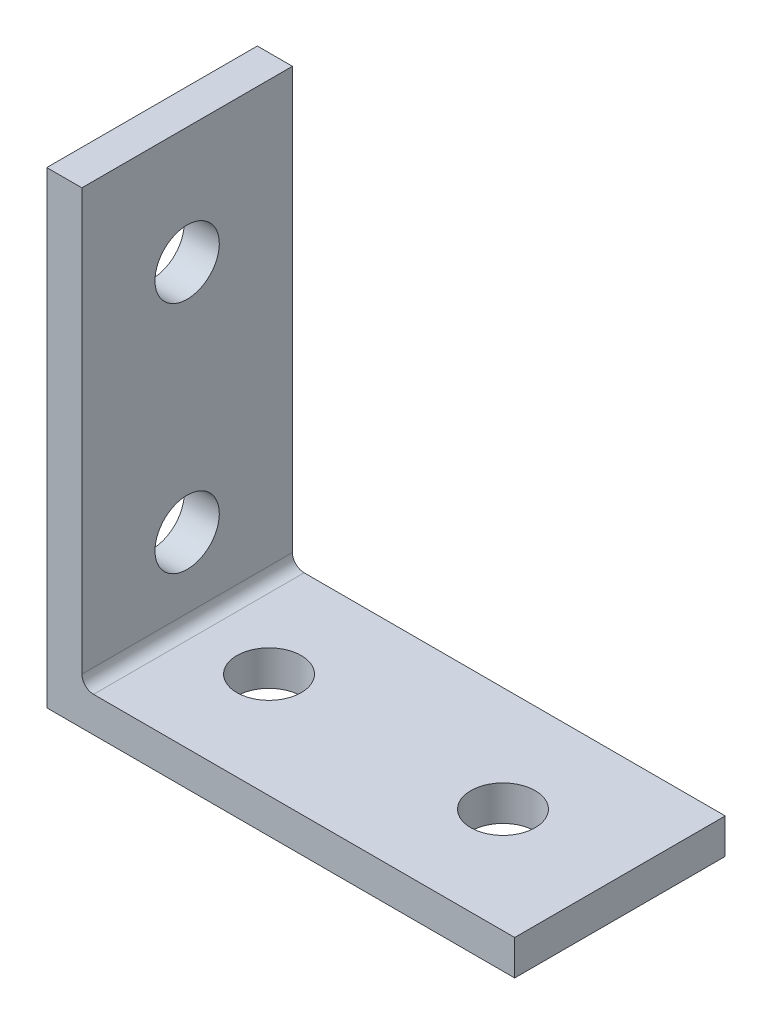
from build123d import *

# Parameters (mm, degrees)
BOSS_EXTRUDE1_DEPTH = 9
SKETCH2_R           = 2.75
CUT_EXTRUDE1_DEPTH  = 4
SKETCH3_R           = 2.75
CUT_EXTRUDE2_DEPTH  = 4


with BuildPart() as part:
    # Sketch1 → Boss-Extrude1 (new body, symmetric)
    with BuildSketch(Plane.XY):
        with BuildLine():
            Line((0, 0), (0, 40))
            Line((0, 40), (3, 40))
            Line((3, 40), (3, 4))
            ThreePointArc((3, 4), (3.292893219, 3.292893219), (4, 3))
            Line((4, 3), (40, 3))
            Line((40, 3), (40, 0))
            Line((40, 0), (0, 0))
        make_face()
    extrude(amount=BOSS_EXTRUDE1_DEPTH, both=True)

    # Sketch2 → Cut-Extrude1 (cut, through all)
    with BuildSketch(Plane(origin=(3, 0, 0), x_dir=(0, 0, -1), z_dir=(1, 0, 0))):
        with Locations((0, 10)):
            Circle(SKETCH2_R)
        with Locations((0, 30)):
            Circle(SKETCH2_R)
    extrude(amount=-CUT_EXTRUDE1_DEPTH, mode=Mode.SUBTRACT)

    # Sketch3 → Cut-Extrude2 (cut, through all)
    with BuildSketch(Plane(origin=(0, 3, 0), x_dir=(1, 0, 0), z_dir=(0, 1, 0))):
        with Locations((10, 0)):
            Circle(SKETCH3_R)
        with Locations((30, 0)):
            Circle(SKETCH3_R)
    extrude(amount=-CUT_EXTRUDE2_DEPTH, mode=Mode.SUBTRACT)


solid = part.part
